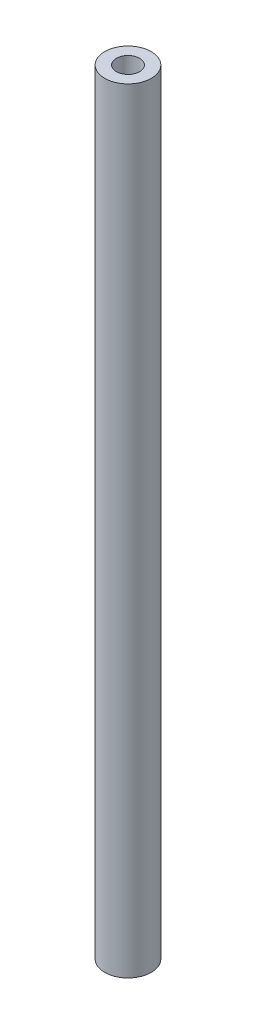
from build123d import *

# Parameters (mm, degrees)
SKETCH_1_R      = 3
SKETCH_1_R_2    = 1.5
EXTRUDE_1_DEPTH = 100


with BuildPart() as part:
    # 草图1 → 凸台-拉伸1 (new body)
    with BuildSketch(Plane(origin=(0, 0, 0), x_dir=(1, 0, 0), z_dir=(0, 1, 0))):
        Circle(SKETCH_1_R)
        Circle(SKETCH_1_R_2, mode=Mode.SUBTRACT)
    extrude(amount=EXTRUDE_1_DEPTH)


solid = part.part
